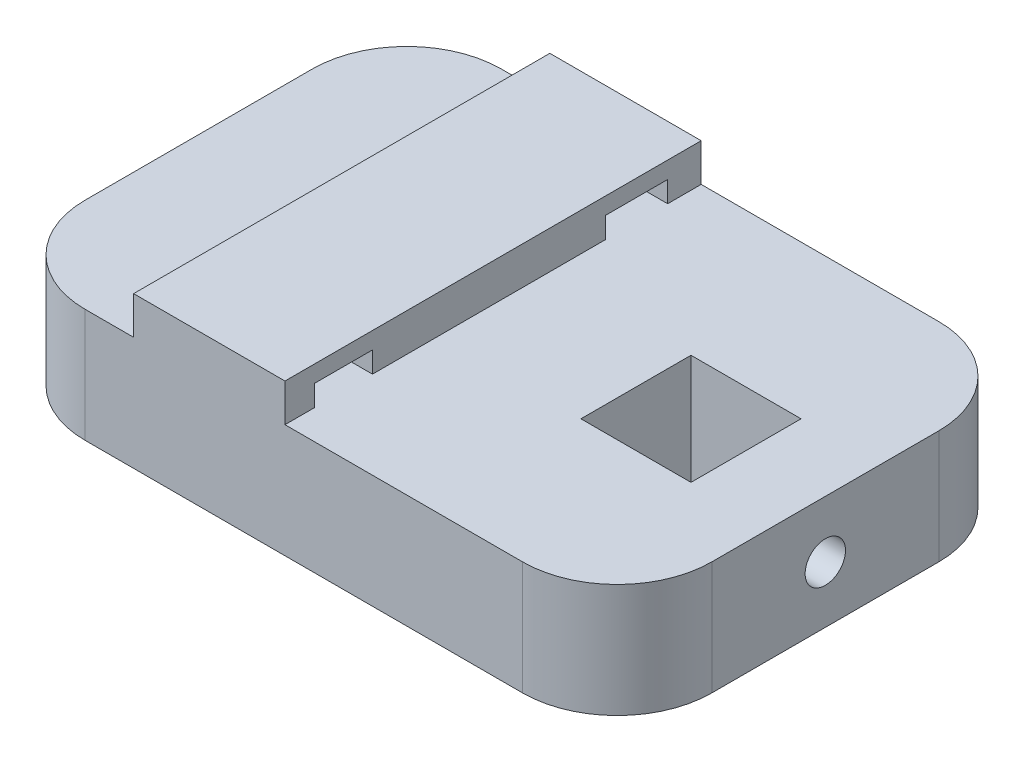
from build123d import *

# Parameters (mm, degrees)
BOSS_EXTRUDE1_DEPTH = 55
SKETCH2_W           = 14.545162339
SKETCH2_H           = 14.545162338
CUT_EXTRUDE1_DEPTH  = 55
SKETCH3_W           = 7.673243051
SKETCH3_H           = 2.777107306
SKETCH3_W_2         = 8.184792588
CUT_EXTRUDE2_DEPTH  = 55
SKETCH4_R           = 2.665972182
CUT_EXTRUDE3_DEPTH  = 20
FILLET1_R           = 12.5


with BuildPart() as part:
    # Sketch1 → Boss-Extrude1 (new body)
    with BuildSketch(Plane.XY):
        Polygon((41.400095641, 5), (28.900095641, 5), (-2.499905164, 5), (-2.499905164, 10), (-22.499903554, 10), (-22.499903554, 5), (-28.900095641, 5), (-41.400095641, 5), (-41.400095641, -10), (-28.900095641, -10), (28.900095641, -10), (41.400095641, -10), align=None)
    extrude(amount=BOSS_EXTRUDE1_DEPTH)

    # Sketch2 → Cut-Extrude1 (cut)
    with BuildSketch(Plane(origin=(0, 5, 0), x_dir=(1, 0, 0), z_dir=(0, 1, 0))):
        with Locations((23.65160359, -27.5)):
            Rectangle(SKETCH2_W, SKETCH2_H)
    extrude(amount=-CUT_EXTRUDE1_DEPTH, mode=Mode.SUBTRACT)

    # Sketch3 → Cut-Extrude2 (cut)
    with BuildSketch(Plane(origin=(-2.499905164, 0, 0), x_dir=(0, 0, -1), z_dir=(1, 0, 0))):
        with Locations((-47.272594324, 6.388553653)):
            Rectangle(SKETCH3_W, SKETCH3_H)
        with Locations((-8.522716918, 6.388553653)):
            Rectangle(SKETCH3_W_2, SKETCH3_H)
    extrude(amount=-CUT_EXTRUDE2_DEPTH, mode=Mode.SUBTRACT)

    # Sketch4 → Cut-Extrude3 (cut)
    with BuildSketch(Plane(origin=(41.400095641, 0, 0), x_dir=(0, 0, -1), z_dir=(1, 0, 0))):
        with Locations((-27.5, -2.516392759)):
            Circle(SKETCH4_R)
    extrude(amount=-CUT_EXTRUDE3_DEPTH, mode=Mode.SUBTRACT)

    # Fillet1
    fillet1_edges = [part.edges().sort_by_distance(p)[0] for p in [
        (-41.400095641, -2.5, 0),
        (41.400095641, -2.5, 0),
        (-41.400095641, -2.5, 55),
        (41.400095641, -2.5, 55),
    ]]
    fillet(fillet1_edges, radius=FILLET1_R)


solid = part.part
